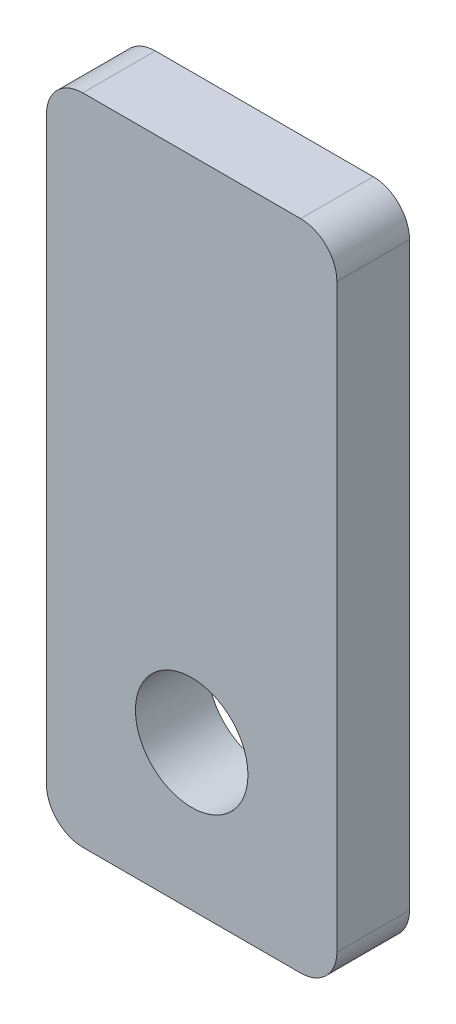
from build123d import *

# Parameters (mm, degrees)
SKETCH_1_R      = 1.55
EXTRUDE_1_DEPTH = 2


with BuildPart() as part:
    # 草图1 → 凸台-拉伸1 (new body)
    with BuildSketch(Plane.XY):
        with BuildLine():
            Line((-3, 9), (3, 9))
            ThreePointArc((3, 9), (3.707106781, 8.707106781), (4, 8))
            Line((4, 8), (4, -8))
            ThreePointArc((4, -8), (3.707106781, -8.707106781), (3, -9))
            Line((3, -9), (-3, -9))
            ThreePointArc((-3, -9), (-3.707106781, -8.707106781), (-4, -8))
            Line((-4, -8), (-4, 8))
            ThreePointArc((-4, 8), (-3.707106781, 8.707106781), (-3, 9))
        make_face()
        with Locations((0, -5)):
            Circle(SKETCH_1_R, mode=Mode.SUBTRACT)
    extrude(amount=EXTRUDE_1_DEPTH)


solid = part.part
